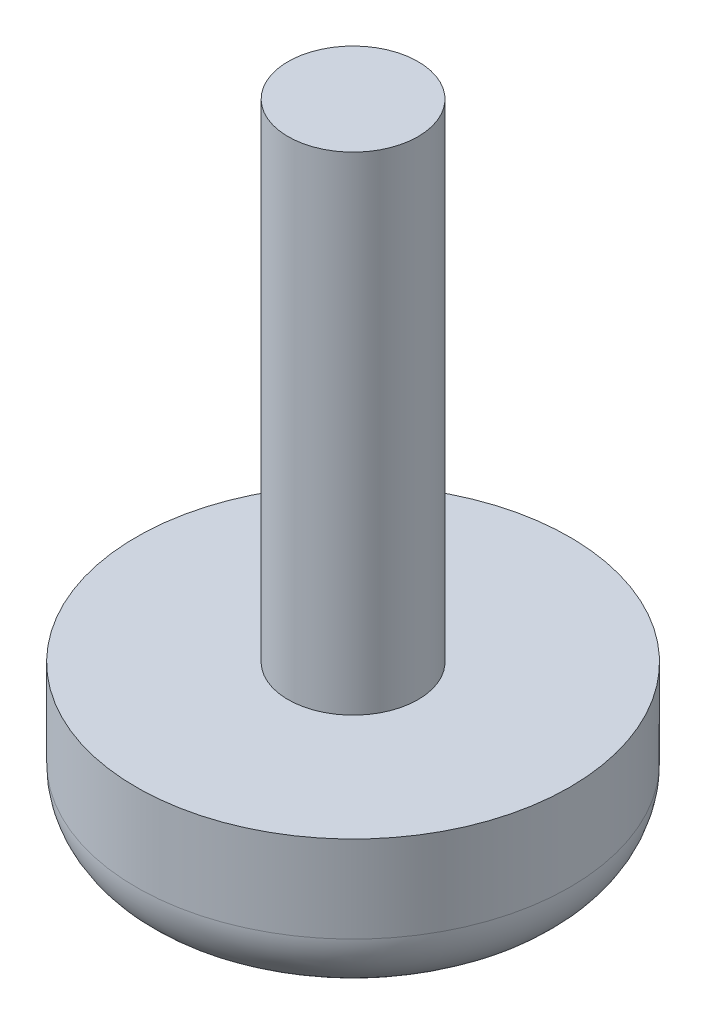
from build123d import *

# Parameters (mm, degrees)
ESQUISSE1_W = 3
ESQUISSE1_H = 22.5
CONG_1_R    = 3


with BuildPart() as part:
    # Esquisse1 → Révolution1 (revolve)
    with BuildSketch(Plane.XY):
        Polygon((0, -7), (0, 0), (-3, 0), (-10, 0), (-10, -7), align=None)
        with Locations((-1.5, 11.25)):
            Rectangle(ESQUISSE1_W, ESQUISSE1_H)
    revolve(axis=Axis((0, 0, 0), (0, 1, 0)))

    # Congé1
    cong_1_edges = [part.edges().sort_by_distance(p)[0] for p in [
        (10, -7, 0),
    ]]
    fillet(cong_1_edges, radius=CONG_1_R)


solid = part.part
